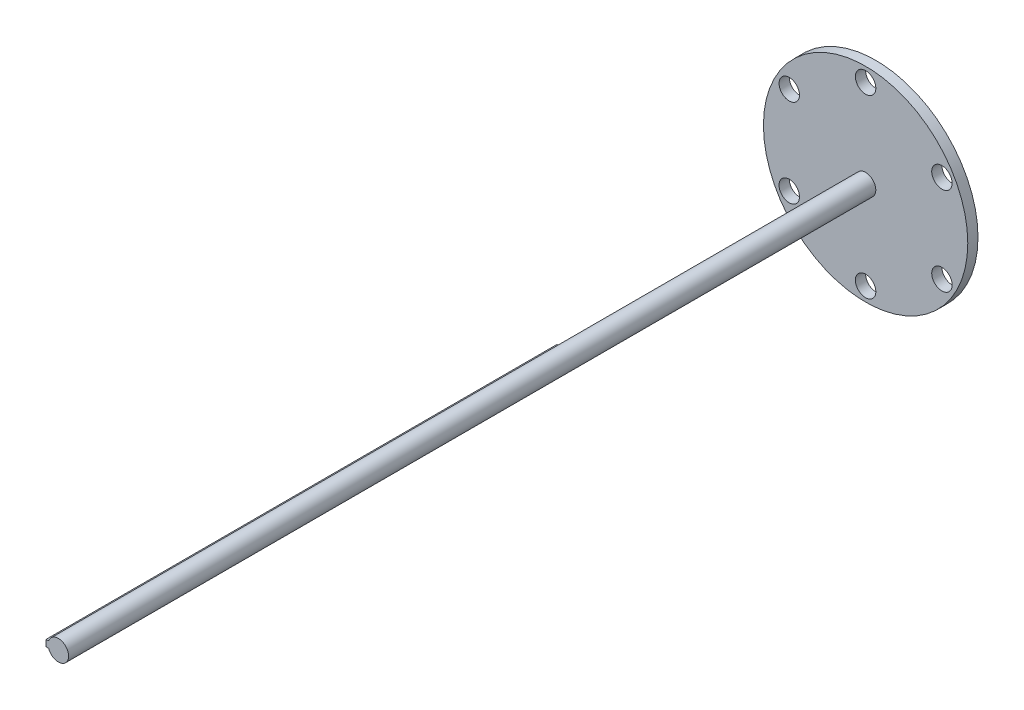
from build123d import *

# Parameters (mm, degrees)
SKETCH_1_R          = 2
EXTRUDE_1_DEPTH     = 160
SKETCH_3_R          = 20
EXTRUDE_2_DEPTH     = 2
SKETCH_4_R          = 2
CUT_EXTRUDE_1_DEPTH = 2
EXTRUDE_3_DEPTH     = 100


with BuildPart() as part:
    # 草图1 → 凸台-拉伸1 (new body)
    with BuildSketch(Plane.XY):
        Circle(SKETCH_1_R)
    extrude(amount=EXTRUDE_1_DEPTH)

    # 草图3 → 凸台-拉伸2 (add)
    with BuildSketch(Plane(origin=(0, 0, 0), x_dir=(-1, 0, 0), z_dir=(0, 0, -1))):
        Circle(SKETCH_3_R)
    extrude(amount=-EXTRUDE_2_DEPTH)

    # 草图4 → 切除-拉伸1 (cut)
    with BuildSketch(Plane(origin=(0, 0, 0), x_dir=(-1, 0, 0), z_dir=(0, 0, -1))):
        with Locations((0, 17.25)):
            Circle(SKETCH_4_R)
        with Locations((14.938938215, 8.625)):
            Circle(SKETCH_4_R)
        with Locations((14.938938215, -8.625)):
            Circle(SKETCH_4_R)
        with Locations((0, -17.25)):
            Circle(SKETCH_4_R)
        with Locations((-14.938938215, -8.625)):
            Circle(SKETCH_4_R)
        with Locations((-14.938938215, 8.625)):
            Circle(SKETCH_4_R)
    extrude(amount=-CUT_EXTRUDE_1_DEPTH, mode=Mode.SUBTRACT)

    # 草图5 → 凸台-拉伸3 (add)
    with BuildSketch(Plane.XY.offset(160)):
        Polygon((-2.419835519, 0), (-2.419835519, 0.625), (-1.899835519, 0.625), (-1.899835519, -0.625), (-2.419835519, -0.625), align=None)
    extrude(amount=-EXTRUDE_3_DEPTH)


solid = part.part
